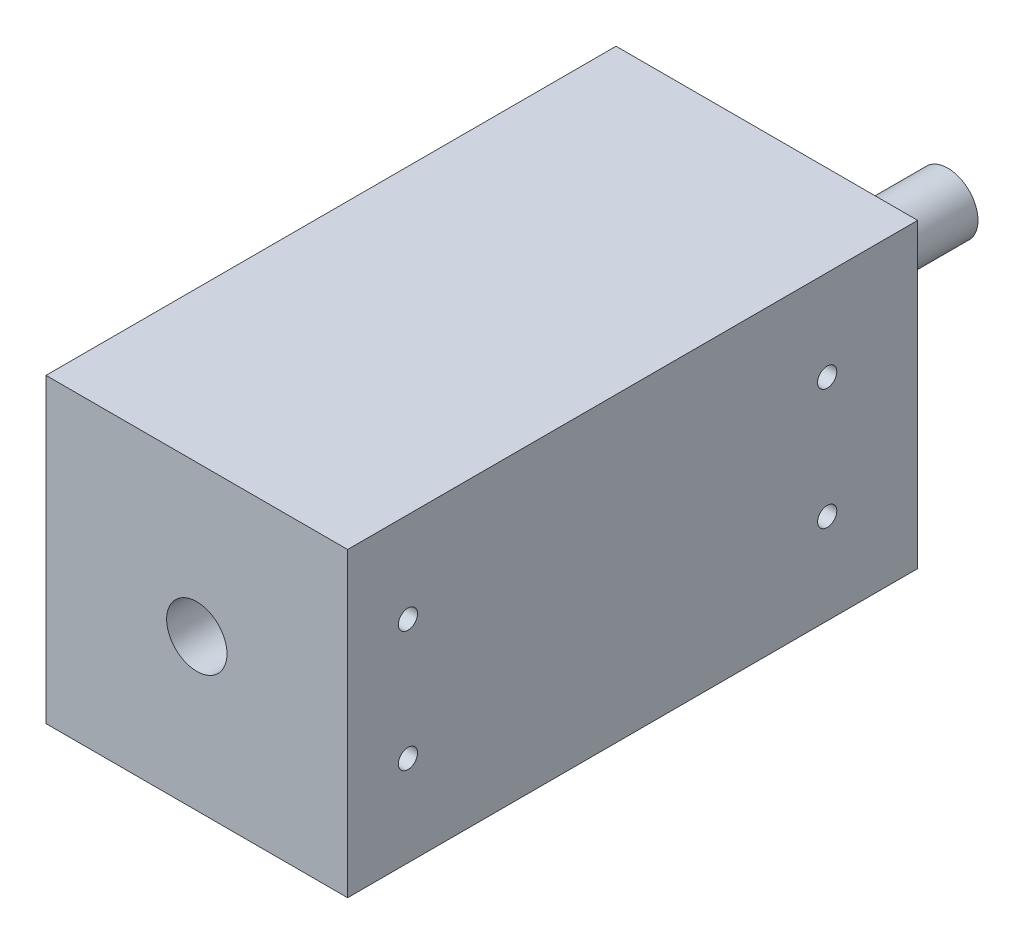
from build123d import *

# Parameters (mm, degrees)
SKETCH1_W              = 63.5
SKETCH1_H              = 63.5
BOSS_EXTRUDE1_DEPTH    = 60.0075
SKETCH2_R              = 6.35
BOSS_EXTRUDE2_DEPTH    = 38.1
SKETCH3_R              = 6.35
CUT_EXTRUDE1_DEPTH     = 38.1
F_10_32_TAPPED_HOLE1_D = 4.0386


with BuildPart() as part:
    # Sketch1 → Boss-Extrude1 (new body, symmetric)
    with BuildSketch(Plane.XY):
        Rectangle(SKETCH1_W, SKETCH1_H)
    extrude(amount=BOSS_EXTRUDE1_DEPTH, both=True)

    # Sketch2 → Boss-Extrude2 (add)
    with BuildSketch(Plane(origin=(0, 0, -60.0075), x_dir=(-1, 0, 0), z_dir=(0, 0, -1))):
        Circle(SKETCH2_R)
    extrude(amount=BOSS_EXTRUDE2_DEPTH)

    # Sketch3 → Cut-Extrude1 (cut)
    with BuildSketch(Plane.XY.offset(60.0075)):
        Circle(SKETCH3_R)
    extrude(amount=-CUT_EXTRUDE1_DEPTH, mode=Mode.SUBTRACT)

    # #10-32 Tapped Hole1 (through all)
    with Locations(Plane.ZY.offset(31.75)):
        with Locations((-40.9575, 12.7), (-40.9575, -12.7), (47.3075, -12.7), (47.3075, 12.7)):
            Hole(F_10_32_TAPPED_HOLE1_D / 2)


solid = part.part
